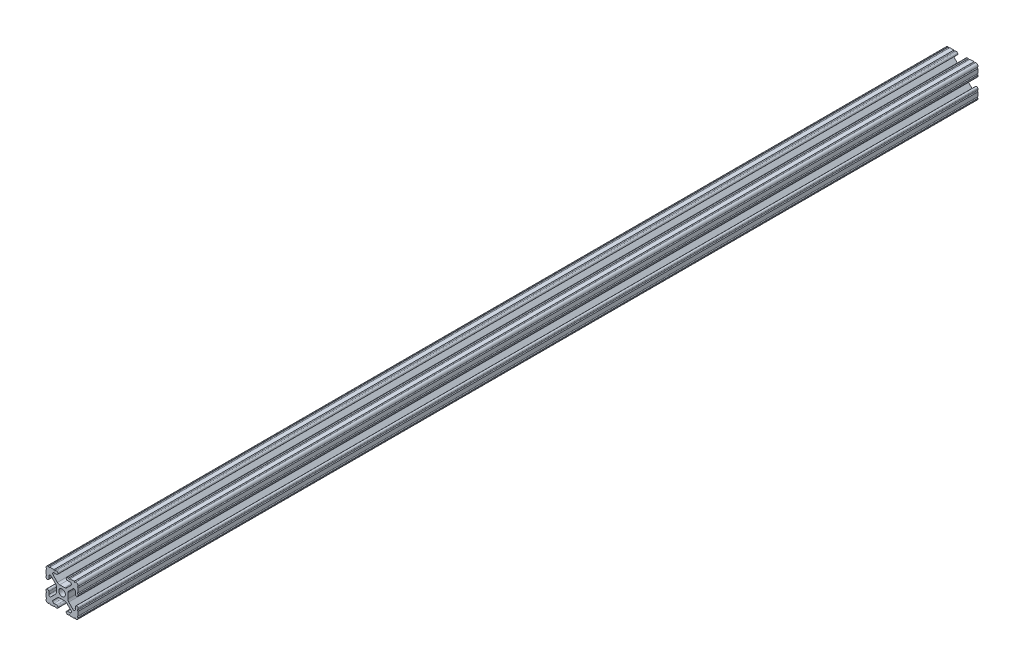
from build123d import *

# Parameters (mm, degrees)
SKETCH3_W                = 25.4
SKETCH3_H                = 25.4
BOSS_EXTRUDE1_DEPTH      = 355.6
BOSS_EXTRUDE1_DEPTH_BACK = 355.6
SKETCH4_R                = 2.6035
CUT_EXTRUDE1_DEPTH       = 712.2
CUT_EXTRUDE2_DEPTH       = 712.2
FILLET1_R                = 2.54
FILLET2_R                = 1.778


with BuildPart() as part:
    # Sketch3 → Boss-Extrude1 (new body, two sides)
    with BuildSketch(Plane.XY) as boss_extrude1_sk:
        Rectangle(SKETCH3_W, SKETCH3_H)
    extrude(amount=BOSS_EXTRUDE1_DEPTH)
    extrude(boss_extrude1_sk.sketch, amount=-BOSS_EXTRUDE1_DEPTH_BACK)

    # Sketch4 → Cut-Extrude1 (cut, through all)
    with BuildSketch(Plane.XY.offset(355.6)):
        with BuildLine():
            Line((3.2512, 12.7), (-3.2512, 12.7))
            Line((-3.2512, 12.7), (-3.2512, 10.4902))
            Line((-3.2512, 10.4902), (-6.348478019, 10.4902))
            ThreePointArc((-6.348478019, 10.4902), (-7.335478831, 9.830707141), (-7.103895736, 8.666460301))
            Line((-7.103895736, 8.666460301), (-2.958635435, 4.5212))
            Line((-2.958635435, 4.5212), (2.958635435, 4.5212))
            Line((2.958635435, 4.5212), (7.103895736, 8.666460301))
            ThreePointArc((7.103895736, 8.666460301), (7.335478831, 9.830707141), (6.348478019, 10.4902))
            Line((6.348478019, 10.4902), (3.2512, 10.4902))
            Line((3.2512, 10.4902), (3.2512, 12.7))
        make_face()
        with BuildLine():
            Line((12.7, -3.2512), (12.7, 3.2512))
            Line((12.7, 3.2512), (10.4902, 3.2512))
            Line((10.4902, 3.2512), (10.4902, 6.348478019))
            ThreePointArc((10.4902, 6.348478019), (9.830707141, 7.335478831), (8.666460301, 7.103895736))
            Line((8.666460301, 7.103895736), (4.5212, 2.958635435))
            Line((4.5212, 2.958635435), (4.5212, -2.958635435))
            Line((4.5212, -2.958635435), (8.666460301, -7.103895736))
            ThreePointArc((8.666460301, -7.103895736), (9.830707141, -7.335478831), (10.4902, -6.348478019))
            Line((10.4902, -6.348478019), (10.4902, -3.2512))
            Line((10.4902, -3.2512), (12.7, -3.2512))
        make_face()
        with BuildLine():
            Line((-3.2512, -10.4902), (-3.2512, -12.7))
            Line((-3.2512, -12.7), (3.2512, -12.7))
            Line((3.2512, -12.7), (3.2512, -10.4902))
            Line((3.2512, -10.4902), (6.348478019, -10.4902))
            ThreePointArc((6.348478019, -10.4902), (7.335478831, -9.830707141), (7.103895736, -8.666460301))
            Line((7.103895736, -8.666460301), (2.958635435, -4.5212))
            Line((2.958635435, -4.5212), (-2.958635435, -4.5212))
            Line((-2.958635435, -4.5212), (-7.103895736, -8.666460301))
            ThreePointArc((-7.103895736, -8.666460301), (-7.335478831, -9.830707141), (-6.348478019, -10.4902))
            Line((-6.348478019, -10.4902), (-3.2512, -10.4902))
        make_face()
        with BuildLine():
            Line((-10.4902, 3.2512), (-12.7, 3.2512))
            Line((-12.7, 3.2512), (-12.7, -3.2512))
            Line((-12.7, -3.2512), (-10.4902, -3.2512))
            Line((-10.4902, -3.2512), (-10.4902, -6.348478019))
            ThreePointArc((-10.4902, -6.348478019), (-9.830707141, -7.335478831), (-8.666460301, -7.103895736))
            Line((-8.666460301, -7.103895736), (-4.5212, -2.958635435))
            Line((-4.5212, -2.958635435), (-4.5212, 2.958635435))
            Line((-4.5212, 2.958635435), (-8.666460301, 7.103895736))
            ThreePointArc((-8.666460301, 7.103895736), (-9.830707141, 7.335478831), (-10.4902, 6.348478019))
            Line((-10.4902, 6.348478019), (-10.4902, 3.2512))
        make_face()
        Circle(SKETCH4_R)
    extrude(amount=-CUT_EXTRUDE1_DEPTH, mode=Mode.SUBTRACT)

    # Sketch5 → Cut-Extrude2 (cut, through all)
    with BuildSketch(Plane.XY.offset(355.6)):
        with BuildLine():
            ThreePointArc((-11.5951, 3.2512), (-12.376382283, 3.574817717), (-12.7, 4.3561))
            Line((-12.7, 4.3561), (-12.7, 3.2512))
            Line((-12.7, 3.2512), (-11.5951, 3.2512))
        make_face()
        with BuildLine():
            ThreePointArc((-10.4902, 4.3561), (-10.813817717, 3.574817717), (-11.5951, 3.2512))
            Line((-11.5951, 3.2512), (-10.4902, 3.2512))
            Line((-10.4902, 3.2512), (-10.4902, 4.3561))
        make_face()
        with BuildLine():
            Line((-12.7, -3.2512), (-12.7, -4.3561))
            ThreePointArc((-12.7, -4.3561), (-12.376382283, -3.574817717), (-11.5951, -3.2512))
            Line((-11.5951, -3.2512), (-12.7, -3.2512))
        make_face()
        with BuildLine():
            Line((-10.4902, -3.2512), (-11.5951, -3.2512))
            ThreePointArc((-11.5951, -3.2512), (-10.813817717, -3.574817717), (-10.4902, -4.3561))
            Line((-10.4902, -4.3561), (-10.4902, -3.2512))
        make_face()
        with BuildLine():
            Line((-3.2512, -11.595100007), (-3.2512, -10.4902))
            Line((-3.2512, -10.4902), (-4.3561, -10.4902))
            ThreePointArc((-4.3561, -10.4902), (-3.574817715, -10.81381772), (-3.2512, -11.595100007))
        make_face()
        with BuildLine():
            Line((-3.2512, -12.7), (-3.2512, -11.595100007))
            ThreePointArc((-3.2512, -11.595100007), (-3.57481772, -12.376382285), (-4.3561, -12.7))
            Line((-4.3561, -12.7), (-3.2512, -12.7))
        make_face()
        with BuildLine():
            Line((3.2512, -10.4902), (3.2512, -11.5951))
            ThreePointArc((3.2512, -11.5951), (3.574817718, -10.813817717), (4.3561, -10.4902))
            Line((4.3561, -10.4902), (3.2512, -10.4902))
        make_face()
        with BuildLine():
            Line((3.2512, -12.7), (4.3561, -12.7))
            ThreePointArc((4.3561, -12.7), (3.574817717, -12.376382282), (3.2512, -11.5951))
            Line((3.2512, -11.5951), (3.2512, -12.7))
        make_face()
        with BuildLine():
            Line((11.5951, -3.2512), (10.4902, -3.2512))
            Line((10.4902, -3.2512), (10.4902, -4.3561))
            ThreePointArc((10.4902, -4.3561), (10.813817717, -3.574817717), (11.5951, -3.2512))
        make_face()
        with BuildLine():
            Line((12.7, -3.2512), (11.5951, -3.2512))
            ThreePointArc((11.5951, -3.2512), (12.376382283, -3.574817717), (12.7, -4.3561))
            Line((12.7, -4.3561), (12.7, -3.2512))
        make_face()
        with BuildLine():
            Line((10.4902, 3.2512), (11.5951, 3.2512))
            ThreePointArc((11.5951, 3.2512), (10.813817717, 3.574817717), (10.4902, 4.3561))
            Line((10.4902, 4.3561), (10.4902, 3.2512))
        make_face()
        with BuildLine():
            Line((12.7, 3.2512), (12.7, 4.3561))
            ThreePointArc((12.7, 4.3561), (12.376382283, 3.574817717), (11.5951, 3.2512))
            Line((11.5951, 3.2512), (12.7, 3.2512))
        make_face()
        with BuildLine():
            Line((3.2512, 12.7), (3.2512, 11.595099996))
            ThreePointArc((3.2512, 11.595099996), (3.574817716, 12.376382281), (4.3561, 12.7))
            Line((4.3561, 12.7), (3.2512, 12.7))
        make_face()
        with BuildLine():
            Line((3.2512, 11.595099996), (3.2512, 10.4902))
            Line((3.2512, 10.4902), (4.3561, 10.4902))
            ThreePointArc((4.3561, 10.4902), (3.574817719, 10.813817716), (3.2512, 11.595099996))
        make_face()
        with BuildLine():
            Line((-3.2512, 12.7), (-4.3561, 12.7))
            ThreePointArc((-4.3561, 12.7), (-3.574817717, 12.376382283), (-3.2512, 11.5951))
            Line((-3.2512, 11.5951), (-3.2512, 12.7))
        make_face()
        with BuildLine():
            Line((-3.2512, 10.4902), (-3.2512, 11.5951))
            ThreePointArc((-3.2512, 11.5951), (-3.574817717, 10.813817717), (-4.3561, 10.4902))
            Line((-4.3561, 10.4902), (-3.2512, 10.4902))
        make_face()
        with BuildLine():
            ThreePointArc((-12.7, 5.23875), (-12.14755, 5.7912), (-12.7, 6.34365))
            Line((-12.7, 6.34365), (-12.7, 5.23875))
        make_face()
        with BuildLine():
            ThreePointArc((-12.7, 9.60755), (-12.14755, 10.16), (-12.7, 10.71245))
            Line((-12.7, 10.71245), (-12.7, 9.60755))
        make_face()
        with BuildLine():
            ThreePointArc((-10.71245, 12.7), (-10.16, 12.14755), (-9.60755, 12.7))
            Line((-9.60755, 12.7), (-10.71245, 12.7))
        make_face()
        with BuildLine():
            ThreePointArc((-6.34365, 12.7), (-5.7912, 12.14755), (-5.23875, 12.7))
            Line((-5.23875, 12.7), (-6.34365, 12.7))
        make_face()
        with BuildLine():
            Line((6.34365, 12.7), (5.23875, 12.7))
            ThreePointArc((5.23875, 12.7), (5.7912, 12.14755), (6.34365, 12.7))
        make_face()
        with BuildLine():
            Line((10.71245, 12.7), (9.60755, 12.7))
            ThreePointArc((9.60755, 12.7), (10.16, 12.14755), (10.71245, 12.7))
        make_face()
        with BuildLine():
            Line((12.7, 10.71245), (12.7, 9.60755))
            ThreePointArc((12.7, 9.60755), (12.14755, 10.16), (12.7, 10.71245))
        make_face()
        with BuildLine():
            Line((12.7, 6.34365), (12.7, 5.23875))
            ThreePointArc((12.7, 5.23875), (12.14755, 5.7912), (12.7, 6.34365))
        make_face()
        with BuildLine():
            Line((-12.7, -6.34365), (-12.7, -5.23875))
            ThreePointArc((-12.7, -5.23875), (-12.14755, -5.7912), (-12.7, -6.34365))
        make_face()
        with BuildLine():
            Line((-12.7, -10.71245), (-12.7, -9.60755))
            ThreePointArc((-12.7, -9.60755), (-12.14755, -10.16), (-12.7, -10.71245))
        make_face()
        with BuildLine():
            Line((-10.71245, -12.7), (-9.60755, -12.7))
            ThreePointArc((-9.60755, -12.7), (-10.16, -12.14755), (-10.71245, -12.7))
        make_face()
        with BuildLine():
            Line((-6.34365, -12.7), (-5.23875, -12.7))
            ThreePointArc((-5.23875, -12.7), (-5.7912, -12.14755), (-6.34365, -12.7))
        make_face()
        with BuildLine():
            Line((12.7, -10.71245), (12.7, -9.60755))
            ThreePointArc((12.7, -9.60755), (12.14755, -10.16), (12.7, -10.71245))
        make_face()
        with BuildLine():
            Line((12.7, -6.34365), (12.7, -5.23875))
            ThreePointArc((12.7, -5.23875), (12.14755, -5.7912), (12.7, -6.34365))
        make_face()
        with BuildLine():
            Line((10.71245, -12.7), (9.60755, -12.7))
            ThreePointArc((9.60755, -12.7), (10.16, -12.14755), (10.71245, -12.7))
        make_face()
        with BuildLine():
            Line((6.34365, -12.7), (5.23875, -12.7))
            ThreePointArc((5.23875, -12.7), (5.7912, -12.14755), (6.34365, -12.7))
        make_face()
    extrude(amount=-CUT_EXTRUDE2_DEPTH, mode=Mode.SUBTRACT)

    # Fillet1
    fillet1_edges = [part.edges().sort_by_distance(p)[0] for p in [
        (2.958635435, 4.5212, 0),
        (-2.958635435, 4.5212, 0),
        (-2.958635435, -4.5212, 0),
        (2.958635435, -4.5212, 0),
        (4.5212, -2.958635435, 0),
        (4.5212, 2.958635435, 0),
        (-4.5212, 2.958635435, 0),
        (-4.5212, -2.958635435, 0),
    ]]
    fillet(fillet1_edges, radius=FILLET1_R)

    # Fillet2
    fillet2_edges = [part.edges().sort_by_distance(p)[0] for p in [
        (-12.7, 12.7, 0),
        (12.7, 12.7, 0),
        (12.7, -12.7, 0),
        (-12.7, -12.7, 0),
    ]]
    fillet(fillet2_edges, radius=FILLET2_R)


solid = part.part
